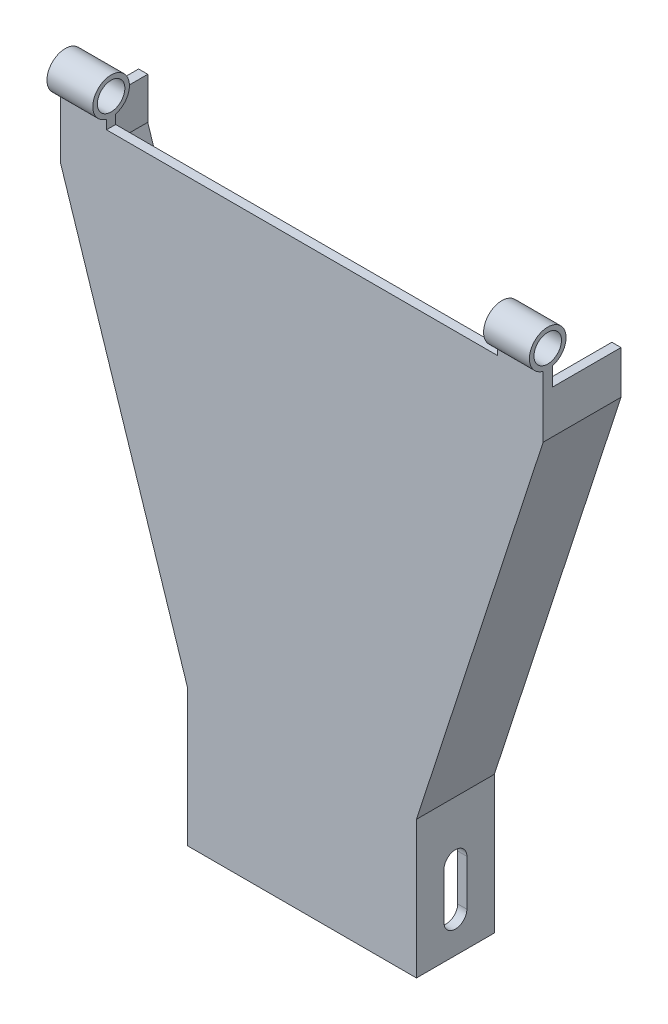
from build123d import *

# Parameters (mm, degrees)
BOSS_EXTRUDE1_START = 4
BOSS_EXTRUDE1_DEPTH = 1
SKETCH2_R           = 4
SKETCH2_R_2         = 3
BOSS_EXTRUDE2_DEPTH = 10
BOSS_EXTRUDE3_DEPTH = 15
CUT_EXTRUDE1_DEPTH  = 78.65


with BuildPart() as part:
    # Sketch1 → Boss-Extrude1 (new body, symmetric)
    with BuildSketch(Plane.XY.offset(BOSS_EXTRUDE1_START)):
        Polygon((-52.65, -30.4), (-25, -115.5), (-25, -145.5), (25, -145.5), (25, -115.5), (52.65, -30.4), (52.65, -17), (42.65, -17), (42.65, -19), (-42.65, -19), (-42.65, -17), (-52.65, -17), align=None)
    extrude(amount=BOSS_EXTRUDE1_DEPTH, both=True)

    # Sketch2 → Boss-Extrude2 (add)
    with BuildSketch(Plane(origin=(52.65, 0, 0), x_dir=(0, 0, -1), z_dir=(1, 0, 0))):
        with Locations((-4, -13.127016654)):
            Circle(SKETCH2_R)
        with Locations((-4, -13.127016654)):
            Circle(SKETCH2_R_2, mode=Mode.SUBTRACT)
    boss_extrude2 = extrude(amount=-BOSS_EXTRUDE2_DEPTH)

    # Sketch3 → Boss-Extrude3 (add)
    with BuildSketch(Plane(origin=(0, 0, 3), x_dir=(-1, 0, 0), z_dir=(0, 0, -1))):
        Polygon((-23, -145.5), (-25, -145.5), (-25, -115.5), (-52.65, -30.4), (-52.65, -21), (-50.65, -21), (-50.65, -30.083238377), (-23, -115.183238377), align=None)
    boss_extrude3 = extrude(amount=BOSS_EXTRUDE3_DEPTH)

    # Sketch7 → Cut-Extrude1 (cut, through all)
    with BuildSketch(Plane(origin=(25, 0, 0), x_dir=(0, 0, -1), z_dir=(1, 0, 0))):
        with BuildLine():
            Line((6, -128), (6, -138))
            ThreePointArc((6, -138), (3.5, -140.5), (1, -138))
            Line((1, -138), (1, -128))
            ThreePointArc((1, -128), (3.5, -125.5), (6, -128))
        make_face()
    cut_extrude1 = extrude(amount=-CUT_EXTRUDE1_DEPTH, mode=Mode.SUBTRACT)

    # Mirror2: Boss-Extrude2, Boss-Extrude3, Cut-Extrude1 across plane
    add(boss_extrude2.mirror(Plane(origin=(0, 0, 0), x_dir=(0, 0, 1), z_dir=(1, 0, 0))))
    add(boss_extrude3.mirror(Plane(origin=(0, 0, 0), x_dir=(0, 0, 1), z_dir=(1, 0, 0))))
    add(cut_extrude1.mirror(Plane(origin=(0, 0, 0), x_dir=(0, 0, 1), z_dir=(1, 0, 0))), mode=Mode.SUBTRACT)


solid = part.part
